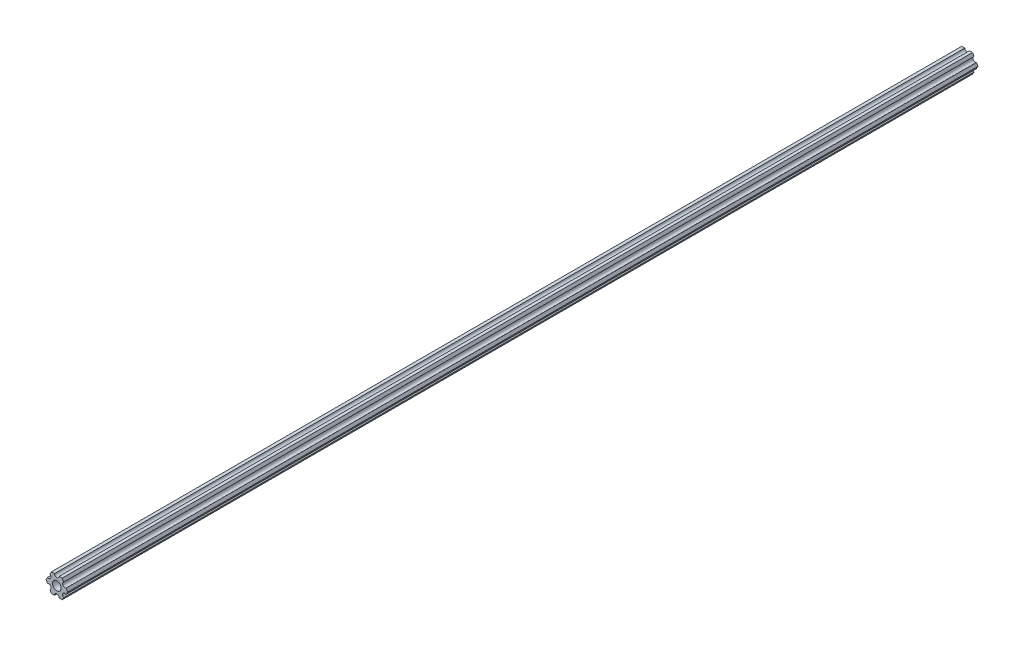
from build123d import *

# Parameters (mm, degrees)
SKETCH1_R           = 2.9337
BOSS_EXTRUDE1_DEPTH = 615.95


with BuildPart() as part:
    # Sketch1 → Boss-Extrude1 (new body)
    with BuildSketch(Plane.XY):
        with BuildLine():
            Line((-1.587500385, 6.349999904), (-3.666174594, 6.349999778))
            Line((-3.666174594, 6.349999778), (-4.70551159, 4.549815043))
            ThreePointArc((-4.70551159, 4.549815043), (-4.12444613, 2.38124975), (-6.293011423, 1.80018429))
            Line((-6.293011423, 1.80018429), (-7.332348419, -4.44e-07))
            Line((-7.332348419, -4.44e-07), (-6.293011205, -1.800185053))
            ThreePointArc((-6.293011205, -1.800185053), (-4.124445841, -2.38125025), (-4.705511038, -4.549815614))
            Line((-4.705511038, -4.549815614), (-3.666173825, -6.350000222))
            Line((-3.666173825, -6.350000222), (-1.587499615, -6.350000096))
            ThreePointArc((-1.587499615, -6.350000096), (2.89e-07, -4.7625), (1.587500385, -6.349999904))
            Line((1.587500385, -6.349999904), (3.666174594, -6.349999778))
            Line((3.666174594, -6.349999778), (4.70551159, -4.549815043))
            ThreePointArc((4.70551159, -4.549815043), (4.12444613, -2.38124975), (6.293011423, -1.80018429))
            Line((6.293011423, -1.80018429), (7.332348419, 4.44e-07))
            Line((7.332348419, 4.44e-07), (6.293011205, 1.800185053))
            ThreePointArc((6.293011205, 1.800185053), (4.124445841, 2.38125025), (4.705511038, 4.549815614))
            Line((4.705511038, 4.549815614), (3.666173825, 6.350000222))
            Line((3.666173825, 6.350000222), (1.587499615, 6.350000096))
            ThreePointArc((1.587499615, 6.350000096), (-2.89e-07, 4.7625), (-1.587500385, 6.349999904))
        make_face()
        Circle(SKETCH1_R, mode=Mode.SUBTRACT)
    extrude(amount=BOSS_EXTRUDE1_DEPTH)


solid = part.part
